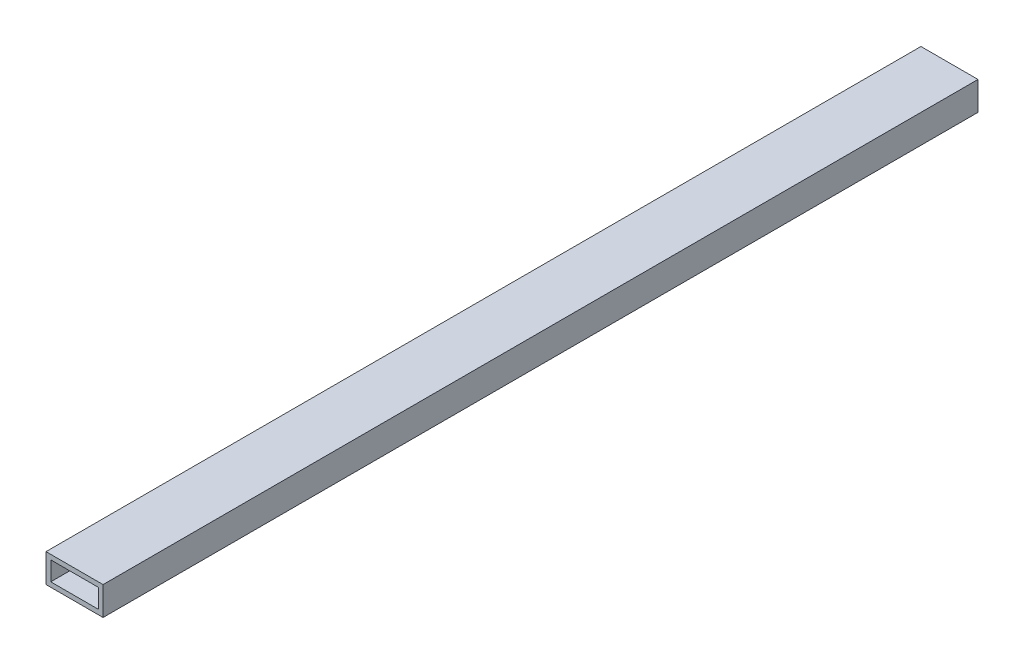
from build123d import *

# Parameters (mm, degrees)
SKETCH1_W           = 38.1
SKETCH1_H           = 19.05
BOSS_EXTRUDE1_DEPTH = 584.2
SKETCH2_W           = 31.75
SKETCH2_H           = 12.7
CUT_EXTRUDE1_DEPTH  = 585.2


with BuildPart() as part:
    # Sketch1 → Boss-Extrude1 (new body)
    with BuildSketch(Plane.XY):
        with Locations((6.491111111, 0.564444444)):
            Rectangle(SKETCH1_W, SKETCH1_H)
    extrude(amount=BOSS_EXTRUDE1_DEPTH)

    # Sketch2 → Cut-Extrude1 (cut, through all)
    with BuildSketch(Plane(origin=(0, 0, 0), x_dir=(-1, 0, 0), z_dir=(0, 0, -1))):
        with Locations((-6.491111111, 0.564444444)):
            Rectangle(SKETCH2_W, SKETCH2_H)
    extrude(amount=-CUT_EXTRUDE1_DEPTH, mode=Mode.SUBTRACT)


solid = part.part
